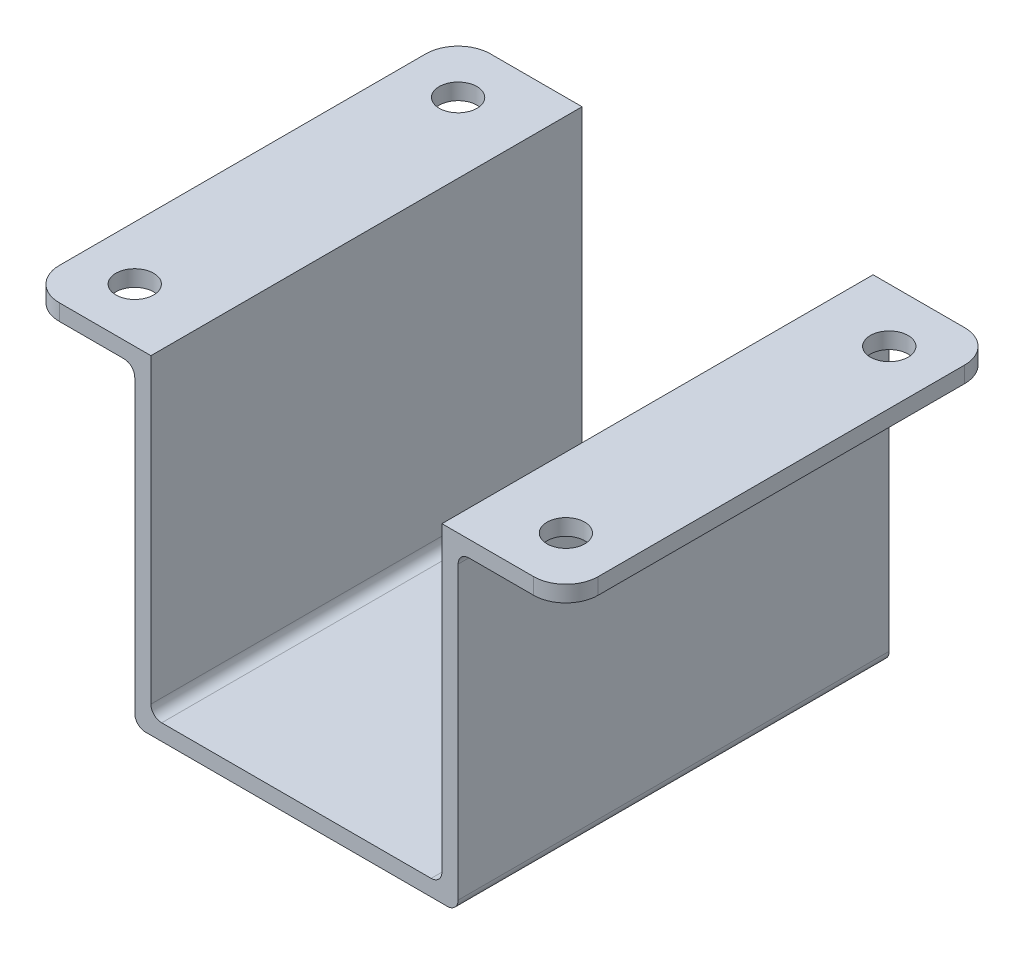
from build123d import *

# Parameters (mm, degrees)
SKETCH1_W           = 30
SKETCH1_H           = 40
SKETCH1_R           = 4.25
BOSS_EXTRUDE1_DEPTH = 1.5
SKETCH2_W           = 40
SKETCH2_H           = 30.5
BOSS_EXTRUDE2_DEPTH = 1.5
SKETCH3_W           = 11.5
SKETCH3_H           = 40
SKETCH3_R           = 1.75
BOSS_EXTRUDE3_DEPTH = 1.5
FILLET1_R           = 1
FILLET2_R           = 3


with BuildPart() as part:
    # Sketch1 → Boss-Extrude1 (new body)
    with BuildSketch(Plane(origin=(0, 0, 0), x_dir=(1, 0, 0), z_dir=(0, 1, 0))):
        Rectangle(SKETCH1_W, SKETCH1_H)
        Circle(SKETCH1_R, mode=Mode.SUBTRACT)
    extrude(amount=BOSS_EXTRUDE1_DEPTH)

    # Sketch2 → Boss-Extrude2 (add)
    with BuildSketch(Plane.ZY.offset(15)):
        with Locations((0, 15.25)):
            Rectangle(SKETCH2_W, SKETCH2_H)
    boss_extrude2 = extrude(amount=-BOSS_EXTRUDE2_DEPTH)

    # Sketch3 → Boss-Extrude3 (add)
    with BuildSketch(Plane(origin=(0, 30.5, 0), x_dir=(1, 0, 0), z_dir=(0, 1, 0))):
        with Locations((-19.25, 0)):
            Rectangle(SKETCH3_W, SKETCH3_H)
        with Locations((-20, 15)):
            Circle(SKETCH3_R, mode=Mode.SUBTRACT)
        with Locations((-20, -15)):
            Circle(SKETCH3_R, mode=Mode.SUBTRACT)
    boss_extrude3 = extrude(amount=-BOSS_EXTRUDE3_DEPTH)

    # Mirror1: Boss-Extrude2, Boss-Extrude3 across plane
    add(boss_extrude2.mirror(Plane(origin=(0, 0, 0), x_dir=(0, 0, 1), z_dir=(1, 0, 0))))
    add(boss_extrude3.mirror(Plane(origin=(0, 0, 0), x_dir=(0, 0, 1), z_dir=(1, 0, 0))))

    # Fillet1
    fillet1_edges = [part.edges().sort_by_distance(p)[0] for p in [
        (-13.5, 1.5, 0),
        (-15, 29, 0),
        (15, 0, 0),
        (-15, 0, 0),
        (13.5, 1.5, 0),
        (15, 29, 0),
    ]]
    fillet(fillet1_edges, radius=FILLET1_R)

    # Fillet2
    fillet2_edges = [part.edges().sort_by_distance(p)[0] for p in [
        (-25, 29.75, -20),
        (-25, 29.75, 20),
        (25, 29.75, 20),
        (25, 29.75, -20),
    ]]
    fillet(fillet2_edges, radius=FILLET2_R)


solid = part.part
